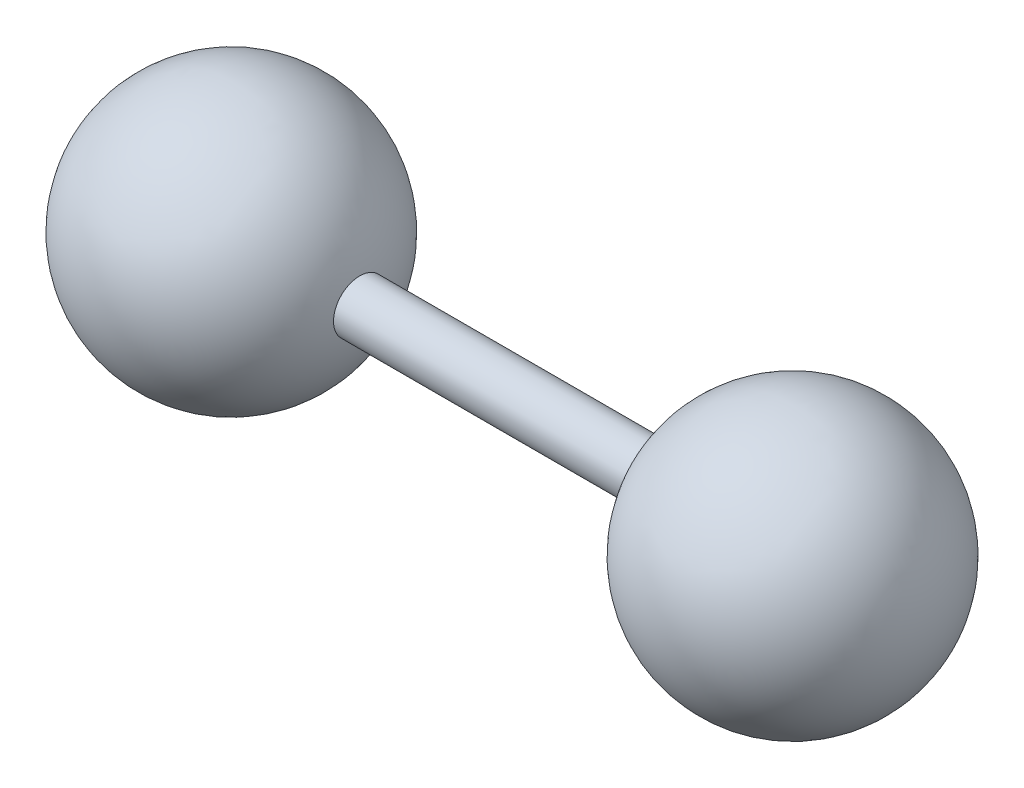
from build123d import *

# Parameters (mm, degrees)
BOSS_EXTRUDE1_DEPTH      = 650
BOSS_EXTRUDE1_DEPTH_BACK = 1800
SKETCH3_R                = 150
SCALE1_SCALE             = 0.5


with BuildPart() as part:
    # Sketch1 → Revolve1 (revolve)
    with BuildSketch(Plane.XY):
        with BuildLine():
            Line((0, 0), (1501.072590683, 0))
            ThreePointArc((1501.072590683, 0), (750.536295342, 750.536295342), (0, 0))
        make_face()
    revolve(axis=Axis((0, 0, 0), (1, 0, 0)))

    # Sketch3 → Boss-Extrude1 (add, two sides: drawn at the far end of the back side and taken through both)
    with BuildSketch(Plane(origin=(0, 0, 0), x_dir=(0, 0, -1), z_dir=(1, 0, 0)).offset(-BOSS_EXTRUDE1_DEPTH_BACK)):
        Circle(SKETCH3_R)
    extrude(amount=BOSS_EXTRUDE1_DEPTH + BOSS_EXTRUDE1_DEPTH_BACK)

    # Sketch4 → Revolve2 (revolve)
    with BuildSketch(Plane.XY):
        with BuildLine():
            Line((-1710.603610822, 0), (-3210.603610822, 0))
            ThreePointArc((-3210.603610822, 0), (-2460.603610822, 750), (-1710.603610822, 0))
        make_face()
    revolve(axis=Axis((-1710.603610822, 0, 0), (-1, 0, 0)))


with BuildPart() as part_1:
    # Scale1: scaled about (-853.378556816, 0, 0)
    add(part.part.scale(SCALE1_SCALE).moved(Location((-426.689278408, 0, 0))))


solid = part_1.part
